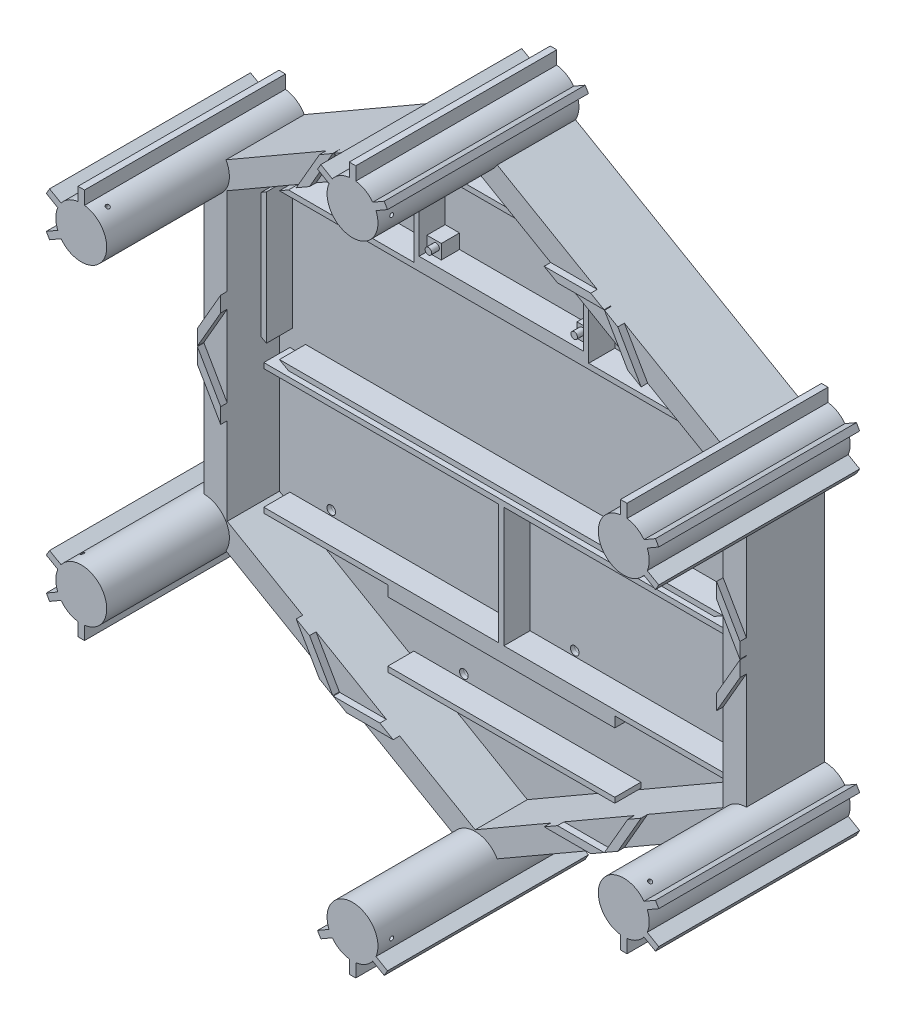
from build123d import *

# Parameters (mm, degrees)
BOSS_EXTRUDE1_DEPTH             = 15
BOSS_EXTRUDE2_REACH             = 163.555
BOSS_EXTRUDE2_DIRECTION_2_DEPTH = 47
CUT_EXTRUDE1_DEPTH              = 20
SKETCH5_W                       = 63
SKETCH5_H                       = 31
SKETCH5_R                       = 1.25
SKETCH5_W_2                     = 87
SKETCH5_H_2                     = 2
BOSS_EXTRUDE3_DEPTH             = 10
SKETCH7_W                       = 5.5
SKETCH7_H                       = 5.5
BOSS_EXTRUDE4_DEPTH             = 7
SKETCH8_R                       = 1.65
CUT_EXTRUDE2_DEPTH              = 1.5
SKETCH9_R                       = 1.8
CUT_EXTRUDE3_DEPTH              = 2.5
BOSS_EXTRUDE9_DEPTH             = 2.5
SKETCH13_R                      = 0.75
CUT_EXTRUDE5_DEPTH              = 267.36610198
SKETCH14_R                      = 0.75
CUT_EXTRUDE6_DEPTH              = 289.120545266
SKETCH15_R                      = 0.75
CUT_EXTRUDE7_DEPTH              = 289.120545266


with BuildPart() as part:
    # Sketch2 → Boss-Extrude1 (new, symmetric)
    with BuildSketch(Plane(origin=(0, 0, 0), x_dir=(0, 1, 0), z_dir=(0, 0, 1))):
        Polygon((120, 0), (60, 103.923048454), (-60, 103.923048454), (-120, 0), (-60, -103.923048454), (60, -103.923048454), align=None)
    extrude(amount=BOSS_EXTRUDE1_DEPTH, both=True)

    # Boss-Extrude2: up to this face of the body (flat: up to its plane)
    boss_extrude2_end = Plane(part.part.faces().sort_by_distance((0, 0, -15))[0])
    # Sketch3 → Boss-Extrude2 (add, up to the picked face)
    with BuildSketch(Plane.XY.offset(15), mode=Mode.PRIVATE) as boss_extrude2_sk1:
        with BuildLine():
            Line((-111.672115566, 54.082698344), (-116.07192316, 51.542468245))
            Line((-116.07192316, 51.542468245), (-117.32192316, 53.707531755))
            Line((-117.32192316, 53.707531755), (-112.922115566, 56.247761853))
            ThreePointArc((-112.922115566, 56.247761853), (-113.673048454, 60), (-112.922115566, 63.752238147))
            Line((-112.922115566, 63.752238147), (-117.32192316, 66.292468245))
            Line((-117.32192316, 66.292468245), (-116.071928769, 68.457524409))
            Line((-116.071928769, 68.457524409), (-111.672121175, 65.917294311))
            ThreePointArc((-111.672121175, 65.917294311), (-108.798052456, 68.443745376), (-105.173048454, 69.669539803))
            Line((-105.173048454, 69.669539803), (-105.173048454, 74.75))
            Line((-105.173048454, 74.75), (-102.673048454, 74.75))
            Line((-102.673048454, 74.75), (-102.673048454, 69.669539803))
            ThreePointArc((-102.673048454, 69.669539803), (-95.479300767, 55.125), (-111.672115566, 54.082698344))
        make_face()
    boss_extrude2_tool1 = split(extrude(boss_extrude2_sk1.sketch, amount=-BOSS_EXTRUDE2_REACH, mode=Mode.PRIVATE), bisect_by=boss_extrude2_end, keep=Keep.BOTH, mode=Mode.PRIVATE)
    # Sketch3 → Boss-Extrude2 (add, up to the picked face)
    with BuildSketch(Plane.XY.offset(15), mode=Mode.PRIVATE) as boss_extrude2_sk2:
        with BuildLine():
            Line((111.672115566, -54.082698344), (116.07192316, -51.542468245))
            Line((116.07192316, -51.542468245), (117.32192316, -53.707531755))
            Line((117.32192316, -53.707531755), (112.922115566, -56.247761853))
            ThreePointArc((112.922115566, -56.247761853), (113.673048454, -60.000004621), (112.92211201, -63.752246677))
            Line((112.92211201, -63.752246677), (117.321919603, -66.292476776))
            Line((117.321919603, -66.292476776), (116.07192316, -68.457531755))
            Line((116.07192316, -68.457531755), (111.672115566, -65.917301656))
            ThreePointArc((111.672115566, -65.917301656), (108.798048454, -68.443747687), (105.173048454, -69.669539803))
            Line((105.173048454, -69.669539803), (105.173048454, -74.75))
            Line((105.173048454, -74.75), (102.673048454, -74.75))
            Line((102.673048454, -74.75), (102.673048454, -69.669539803))
            ThreePointArc((102.673048454, -69.669539803), (95.479300767, -55.125), (111.672115566, -54.082698344))
        make_face()
    boss_extrude2_tool2 = split(extrude(boss_extrude2_sk2.sketch, amount=-BOSS_EXTRUDE2_REACH, mode=Mode.PRIVATE), bisect_by=boss_extrude2_end, keep=Keep.BOTH, mode=Mode.PRIVATE)
    # Sketch3 → Boss-Extrude2 (add, up to the picked face)
    with BuildSketch(Plane.XY.offset(15), mode=Mode.PRIVATE) as boss_extrude2_sk3:
        with BuildLine():
            Line((-8.999067112, 123.752238147), (-13.398874706, 126.292468245))
            Line((-13.398874706, 126.292468245), (-12.148874706, 128.457531755))
            Line((-12.148874706, 128.457531755), (-7.749067112, 125.917301656))
            ThreePointArc((-7.749067112, 125.917301656), (-4.874995998, 128.443749997), (-1.249990834, 129.669540988))
            Line((-1.249990834, 129.669540988), (-1.249990834, 134.750001185))
            Line((-1.249990834, 134.750001185), (1.25, 134.75))
            Line((1.25, 134.75), (1.25, 129.669539803))
            ThreePointArc((1.25, 129.669539803), (4.875, 128.443747687), (7.749067112, 125.917301656))
            Line((7.749067112, 125.917301656), (12.148874706, 128.457531755))
            Line((12.148874706, 128.457531755), (13.398874706, 126.292468245))
            Line((13.398874706, 126.292468245), (8.999067112, 123.752238147))
            ThreePointArc((8.999067112, 123.752238147), (0, 110.25), (-8.999067112, 123.752238147))
        make_face()
    boss_extrude2_tool3 = split(extrude(boss_extrude2_sk3.sketch, amount=-BOSS_EXTRUDE2_REACH, mode=Mode.PRIVATE), bisect_by=boss_extrude2_end, keep=Keep.BOTH, mode=Mode.PRIVATE)
    # Sketch3 → Boss-Extrude2 (add, up to the picked face)
    with BuildSketch(Plane.XY.offset(15), mode=Mode.PRIVATE) as boss_extrude2_sk4:
        with BuildLine():
            Line((-117.32192316, -53.707531755), (-116.07192316, -51.542468245))
            Line((-116.07192316, -51.542468245), (-111.672115566, -54.082698344))
            ThreePointArc((-111.672115566, -54.082698344), (-95.479300767, -55.125), (-102.673048454, -69.669539803))
            Line((-102.673048454, -69.669539803), (-102.673048454, -74.75))
            Line((-102.673048454, -74.75), (-105.173048454, -74.75))
            Line((-105.173048454, -74.75), (-105.173048454, -69.669539803))
            ThreePointArc((-105.173048454, -69.669539803), (-108.798052456, -68.443745376), (-111.672121175, -65.917294311))
            Line((-111.672121175, -65.917294311), (-116.071928769, -68.457524409))
            Line((-116.071928769, -68.457524409), (-117.32192316, -66.292468245))
            Line((-117.32192316, -66.292468245), (-112.922115566, -63.752238147))
            ThreePointArc((-112.922115566, -63.752238147), (-113.673048454, -60), (-112.922115566, -56.247761853))
            Line((-112.922115566, -56.247761853), (-117.32192316, -53.707531755))
        make_face()
    boss_extrude2_tool4 = split(extrude(boss_extrude2_sk4.sketch, amount=-BOSS_EXTRUDE2_REACH, mode=Mode.PRIVATE), bisect_by=boss_extrude2_end, keep=Keep.BOTH, mode=Mode.PRIVATE)
    # Sketch3 → Boss-Extrude2 (add, up to the picked face)
    with BuildSketch(Plane.XY.offset(15), mode=Mode.PRIVATE) as boss_extrude2_sk5:
        with BuildLine():
            Line((102.673048454, 69.669539803), (102.673048454, 74.75))
            Line((102.673048454, 74.75), (105.173048454, 74.75))
            Line((105.173048454, 74.75), (105.173048454, 69.669539803))
            ThreePointArc((105.173048454, 69.669539803), (108.798048454, 68.443747687), (111.672115566, 65.917301656))
            Line((111.672115566, 65.917301656), (116.07192316, 68.457531755))
            Line((116.07192316, 68.457531755), (117.321919603, 66.292476776))
            Line((117.321919603, 66.292476776), (112.92211201, 63.752246677))
            ThreePointArc((112.92211201, 63.752246677), (113.673048454, 60.000004621), (112.922115566, 56.247761853))
            Line((112.922115566, 56.247761853), (117.32192316, 53.707531755))
            Line((117.32192316, 53.707531755), (116.07192316, 51.542468245))
            Line((116.07192316, 51.542468245), (111.672115566, 54.082698344))
            ThreePointArc((111.672115566, 54.082698344), (95.479300767, 55.125), (102.673048454, 69.669539803))
        make_face()
    boss_extrude2_tool5 = split(extrude(boss_extrude2_sk5.sketch, amount=-BOSS_EXTRUDE2_REACH, mode=Mode.PRIVATE), bisect_by=boss_extrude2_end, keep=Keep.BOTH, mode=Mode.PRIVATE)
    # Sketch3 → Boss-Extrude2 (add, up to the picked face)
    with BuildSketch(Plane.XY.offset(15), mode=Mode.PRIVATE) as boss_extrude2_sk6:
        with BuildLine():
            Line((8.999067112, -123.752238147), (13.398874706, -126.292468245))
            Line((13.398874706, -126.292468245), (12.148874706, -128.457531755))
            Line((12.148874706, -128.457531755), (7.749067112, -125.917301656))
            ThreePointArc((7.749067112, -125.917301656), (4.875, -128.443747687), (1.25, -129.669539803))
            Line((1.25, -129.669539803), (1.25, -134.75))
            Line((1.25, -134.75), (-1.249990834, -134.750001185))
            Line((-1.249990834, -134.750001185), (-1.249990834, -129.669540988))
            ThreePointArc((-1.249990834, -129.669540988), (-4.874995998, -128.443749997), (-7.749067112, -125.917301656))
            Line((-7.749067112, -125.917301656), (-12.148874706, -128.457531755))
            Line((-12.148874706, -128.457531755), (-13.398874706, -126.292468245))
            Line((-13.398874706, -126.292468245), (-8.999067112, -123.752238147))
            ThreePointArc((-8.999067112, -123.752238147), (0, -110.25), (8.999067112, -123.752238147))
        make_face()
    boss_extrude2_tool6 = split(extrude(boss_extrude2_sk6.sketch, amount=-BOSS_EXTRUDE2_REACH, mode=Mode.PRIVATE), bisect_by=boss_extrude2_end, keep=Keep.BOTH, mode=Mode.PRIVATE)
    add(boss_extrude2_tool1.solids().sort_by(Axis((-104.714928, 60.457192, 15), (0, 0, -1)))[0])
    add(boss_extrude2_tool2.solids().sort_by(Axis((104.714928, -60.457192, 15), (0, 0, -1)))[0])
    add(boss_extrude2_tool3.solids().sort_by(Axis((0, 120.914384, 15), (0, 0, -1)))[0])
    add(boss_extrude2_tool4.solids().sort_by(Axis((-104.714928, -60.457192, 15), (0, 0, -1)))[0])
    add(boss_extrude2_tool5.solids().sort_by(Axis((104.714928, 60.457192, 15), (0, 0, -1)))[0])
    add(boss_extrude2_tool6.solids().sort_by(Axis((0, -120.914384, 15), (0, 0, -1)))[0])

    # Sketch3 → Boss-Extrude2 direction 2 (add)
    with BuildSketch(Plane.XY.offset(15)):
        with BuildLine():
            Line((-111.672115566, 54.082698344), (-116.07192316, 51.542468245))
            Line((-116.07192316, 51.542468245), (-117.32192316, 53.707531755))
            Line((-117.32192316, 53.707531755), (-112.922115566, 56.247761853))
            ThreePointArc((-112.922115566, 56.247761853), (-113.673048454, 60), (-112.922115566, 63.752238147))
            Line((-112.922115566, 63.752238147), (-117.32192316, 66.292468245))
            Line((-117.32192316, 66.292468245), (-116.071928769, 68.457524409))
            Line((-116.071928769, 68.457524409), (-111.672121175, 65.917294311))
            ThreePointArc((-111.672121175, 65.917294311), (-108.798052456, 68.443745376), (-105.173048454, 69.669539803))
            Line((-105.173048454, 69.669539803), (-105.173048454, 74.75))
            Line((-105.173048454, 74.75), (-102.673048454, 74.75))
            Line((-102.673048454, 74.75), (-102.673048454, 69.669539803))
            ThreePointArc((-102.673048454, 69.669539803), (-95.479300767, 55.125), (-111.672115566, 54.082698344))
        make_face()
        with BuildLine():
            Line((111.672115566, -54.082698344), (116.07192316, -51.542468245))
            Line((116.07192316, -51.542468245), (117.32192316, -53.707531755))
            Line((117.32192316, -53.707531755), (112.922115566, -56.247761853))
            ThreePointArc((112.922115566, -56.247761853), (113.673048454, -60.000004621), (112.92211201, -63.752246677))
            Line((112.92211201, -63.752246677), (117.321919603, -66.292476776))
            Line((117.321919603, -66.292476776), (116.07192316, -68.457531755))
            Line((116.07192316, -68.457531755), (111.672115566, -65.917301656))
            ThreePointArc((111.672115566, -65.917301656), (108.798048454, -68.443747687), (105.173048454, -69.669539803))
            Line((105.173048454, -69.669539803), (105.173048454, -74.75))
            Line((105.173048454, -74.75), (102.673048454, -74.75))
            Line((102.673048454, -74.75), (102.673048454, -69.669539803))
            ThreePointArc((102.673048454, -69.669539803), (95.479300767, -55.125), (111.672115566, -54.082698344))
        make_face()
        with BuildLine():
            Line((-8.999067112, 123.752238147), (-13.398874706, 126.292468245))
            Line((-13.398874706, 126.292468245), (-12.148874706, 128.457531755))
            Line((-12.148874706, 128.457531755), (-7.749067112, 125.917301656))
            ThreePointArc((-7.749067112, 125.917301656), (-4.874995998, 128.443749997), (-1.249990834, 129.669540988))
            Line((-1.249990834, 129.669540988), (-1.249990834, 134.750001185))
            Line((-1.249990834, 134.750001185), (1.25, 134.75))
            Line((1.25, 134.75), (1.25, 129.669539803))
            ThreePointArc((1.25, 129.669539803), (4.875, 128.443747687), (7.749067112, 125.917301656))
            Line((7.749067112, 125.917301656), (12.148874706, 128.457531755))
            Line((12.148874706, 128.457531755), (13.398874706, 126.292468245))
            Line((13.398874706, 126.292468245), (8.999067112, 123.752238147))
            ThreePointArc((8.999067112, 123.752238147), (0, 110.25), (-8.999067112, 123.752238147))
        make_face()
        with BuildLine():
            Line((-117.32192316, -53.707531755), (-116.07192316, -51.542468245))
            Line((-116.07192316, -51.542468245), (-111.672115566, -54.082698344))
            ThreePointArc((-111.672115566, -54.082698344), (-95.479300767, -55.125), (-102.673048454, -69.669539803))
            Line((-102.673048454, -69.669539803), (-102.673048454, -74.75))
            Line((-102.673048454, -74.75), (-105.173048454, -74.75))
            Line((-105.173048454, -74.75), (-105.173048454, -69.669539803))
            ThreePointArc((-105.173048454, -69.669539803), (-108.798052456, -68.443745376), (-111.672121175, -65.917294311))
            Line((-111.672121175, -65.917294311), (-116.071928769, -68.457524409))
            Line((-116.071928769, -68.457524409), (-117.32192316, -66.292468245))
            Line((-117.32192316, -66.292468245), (-112.922115566, -63.752238147))
            ThreePointArc((-112.922115566, -63.752238147), (-113.673048454, -60), (-112.922115566, -56.247761853))
            Line((-112.922115566, -56.247761853), (-117.32192316, -53.707531755))
        make_face()
        with BuildLine():
            Line((102.673048454, 69.669539803), (102.673048454, 74.75))
            Line((102.673048454, 74.75), (105.173048454, 74.75))
            Line((105.173048454, 74.75), (105.173048454, 69.669539803))
            ThreePointArc((105.173048454, 69.669539803), (108.798048454, 68.443747687), (111.672115566, 65.917301656))
            Line((111.672115566, 65.917301656), (116.07192316, 68.457531755))
            Line((116.07192316, 68.457531755), (117.321919603, 66.292476776))
            Line((117.321919603, 66.292476776), (112.92211201, 63.752246677))
            ThreePointArc((112.92211201, 63.752246677), (113.673048454, 60.000004621), (112.922115566, 56.247761853))
            Line((112.922115566, 56.247761853), (117.32192316, 53.707531755))
            Line((117.32192316, 53.707531755), (116.07192316, 51.542468245))
            Line((116.07192316, 51.542468245), (111.672115566, 54.082698344))
            ThreePointArc((111.672115566, 54.082698344), (95.479300767, 55.125), (102.673048454, 69.669539803))
        make_face()
        with BuildLine():
            Line((8.999067112, -123.752238147), (13.398874706, -126.292468245))
            Line((13.398874706, -126.292468245), (12.148874706, -128.457531755))
            Line((12.148874706, -128.457531755), (7.749067112, -125.917301656))
            ThreePointArc((7.749067112, -125.917301656), (4.875, -128.443747687), (1.25, -129.669539803))
            Line((1.25, -129.669539803), (1.25, -134.75))
            Line((1.25, -134.75), (-1.249990834, -134.750001185))
            Line((-1.249990834, -134.750001185), (-1.249990834, -129.669540988))
            ThreePointArc((-1.249990834, -129.669540988), (-4.874995998, -128.443749997), (-7.749067112, -125.917301656))
            Line((-7.749067112, -125.917301656), (-12.148874706, -128.457531755))
            Line((-12.148874706, -128.457531755), (-13.398874706, -126.292468245))
            Line((-13.398874706, -126.292468245), (-8.999067112, -123.752238147))
            ThreePointArc((-8.999067112, -123.752238147), (0, -110.25), (8.999067112, -123.752238147))
        make_face()
    extrude(amount=BOSS_EXTRUDE2_DIRECTION_2_DEPTH)

    # Sketch4 → Cut-Extrude1 (cut)
    with BuildSketch(Plane.XY.offset(15)):
        Polygon((0, 109.696551146), (-95, 54.848275573), (-95, -54.848275573), (0, -109.696551146), (95, -54.848275573), (95, 54.848275573), align=None)
    extrude(amount=-CUT_EXTRUDE1_DEPTH, mode=Mode.SUBTRACT)

    # Sketch5 → Boss-Extrude3 (add)
    with BuildSketch(Plane.XY.offset(-5)):
        Polygon((-1, -53.151724427), (-91, -53.151724427), (-91, -55.151724427), (-43.5, -55.151724427), (-43.5, -59.151724427), (43.5, -59.151724427), (43.5, -55.151724427), (91, -55.151724427), (91, -53.151724427), (1, -53.151724427), (1, -7.151724427), (91, -7.151724427), (91, -5.151724427), (-91, -5.151724427), (-91, -7.151724427), (-1, -7.151724427), align=None)
        Polygon((-90, 1.735026919), (-90, 51.961524227), (-92, 50.806823689), (-92, 2.889727457), align=None)
        Polygon((90, 1.735026919), (90, 51.961524227), (92, 50.806823689), (92, 2.889727457), align=None)
        Polygon((33.5, 56.848275573), (33.5, 92.848275573), (-33.5, 92.848275573), (-33.5, 56.848275573), (-81.535898385, 56.848275573), (-85, 54.848275573), (85, 54.848275573), (81.535898385, 56.848275573), align=None)
        with Locations((0, 75.348275573)):
            Rectangle(SKETCH5_W, SKETCH5_H, mode=Mode.SUBTRACT)
        with Locations((-27.95, 63.298275573)):
            Circle(SKETCH5_R)
        with Locations((27.95, 63.298275573)):
            Circle(SKETCH5_R)
        with Locations((27.95, 86.898275573)):
            Circle(SKETCH5_R)
        with Locations((-27.95, 86.898275573)):
            Circle(SKETCH5_R)
        with Locations((0, -83.151724427)):
            Rectangle(SKETCH5_W_2, SKETCH5_H_2)
        Polygon((-81.535898385, -3.151724427), (81.535898385, -3.151724427), (85, -1.151724427), (-85, -1.151724427), align=None)
    extrude(amount=BOSS_EXTRUDE3_DEPTH)

    # Sketch7 → Boss-Extrude4 (add)
    with BuildSketch(Plane.XY.offset(-5)):
        with Locations((28.75, 88.098275573)):
            Rectangle(SKETCH7_W, SKETCH7_H)
        with Locations((-28.75, 88.098275573)):
            Rectangle(SKETCH7_W, SKETCH7_H)
        with Locations((-28.75, 62.598275573)):
            Rectangle(SKETCH7_W, SKETCH7_H)
        with Locations((28.75, 62.598275573)):
            Rectangle(SKETCH7_W, SKETCH7_H)
    extrude(amount=BOSS_EXTRUDE4_DEPTH)

    # Sketch8 → Cut-Extrude2 (cut)
    with BuildSketch(Plane.XY.offset(-5)):
        with Locations((-75.15, -51.151724427)):
            Circle(SKETCH8_R)
        with Locations((-19.85, -9.151724427)):
            Circle(SKETCH8_R)
        with Locations((18.15, -51.151724427)):
            Circle(SKETCH8_R)
        with Locations((71.85, -9.151724427)):
            Circle(SKETCH8_R)
        with Locations((-24.35, -80.151724427)):
            Circle(SKETCH8_R)
        with Locations((24.35, -61.151724427)):
            Circle(SKETCH8_R)
    extrude(amount=-CUT_EXTRUDE2_DEPTH, mode=Mode.SUBTRACT)

    # Sketch9 → Cut-Extrude3 (cut)
    with BuildSketch(Plane.XY.offset(-6.5)):
        with Locations((-75.15, -51.151724427)):
            Circle(SKETCH9_R)
        with Locations((-19.85, -9.151724427)):
            Circle(SKETCH9_R)
        with Locations((18.15, -51.151724427)):
            Circle(SKETCH9_R)
        with Locations((24.35, -61.151724427)):
            Circle(SKETCH9_R)
        with Locations((-24.35, -80.151724427)):
            Circle(SKETCH9_R)
        with Locations((71.85, -9.151724427)):
            Circle(SKETCH9_R)
    extrude(amount=-CUT_EXTRUDE3_DEPTH, mode=Mode.SUBTRACT)

    # Sketch10 → Boss-Extrude9 (add)
    with BuildSketch(Plane.XY.offset(15)):
        Polygon((60.971175222, -74.494826719), (52.048126767, -89.95), (57.15767665, -87), (66.080725104, -71.544826719), align=None)
        Polygon((-66.080725104, -71.544826719), (-57.15767665, -87), (-52.048126767, -89.95), (-60.971175222, -74.494826719), align=None)
        Polygon((-46.765371804, -93), (-28.919274896, -93), (-34.028824778, -90.05), (-51.874921687, -90.05), align=None)
        Polygon((95, -15.555173281), (95, -21.455173281), (103.923048454, -6), (103.923048454, -0.1), align=None)
        Polygon((-95, -15.555173281), (-103.923048454, -0.1), (-103.923048454, -6), (-95, -21.455173281), align=None)
        Polygon((51.874921687, -90.05), (34.028824778, -90.05), (28.919274896, -93), (46.765371804, -93), align=None)
        Polygon((103.923048454, 0.1), (103.923048454, 6), (95, 21.455173281), (95, 15.555173281), align=None)
        Polygon((34.028824778, 90.05), (51.874921687, 90.05), (46.765371804, 93), (28.919274896, 93), align=None)
        Polygon((52.048126767, 89.95), (60.971175222, 74.494826719), (66.080725104, 71.544826719), (57.15767665, 87), align=None)
        Polygon((-103.923048454, 0.1), (-95, 15.555173281), (-95, 21.455173281), (-103.923048454, 6), align=None)
        Polygon((-52.048126767, 89.95), (-57.15767665, 87), (-66.080725104, 71.544826719), (-60.971175222, 74.494826719), align=None)
        Polygon((-34.028824778, 90.05), (-28.919274896, 93), (-46.765371804, 93), (-51.874921687, 90.05), align=None)
    extrude(amount=BOSS_EXTRUDE9_DEPTH)

    # Sketch13 → Cut-Extrude5 (cut, through all)
    with BuildSketch(Plane.YZ.offset(103.923048454)):
        with Locations((-120, 56.75)):
            Circle(SKETCH13_R)
        with Locations((120, 56.75)):
            Circle(SKETCH13_R)
    extrude(amount=-CUT_EXTRUDE5_DEPTH, mode=Mode.SUBTRACT)

    # Sketch14 → Cut-Extrude6 (cut, through all)
    with BuildSketch(Plane(origin=(51.961524227, -90, 0), x_dir=(0.8660254037844357, 0.5000000000000052, 0), z_dir=(0.5000000000000052, -0.8660254037844357, 0))):
        with Locations((-120, 56.75)):
            Circle(SKETCH14_R)
        with Locations((120, 56.75)):
            Circle(SKETCH14_R)
    extrude(amount=-CUT_EXTRUDE6_DEPTH, mode=Mode.SUBTRACT)

    # Sketch15 → Cut-Extrude7 (cut, through all)
    with BuildSketch(Plane(origin=(-51.961524227, -90, 0), x_dir=(0.8660254037844417, -0.4999999999999949, 0), z_dir=(-0.4999999999999949, -0.8660254037844417, 0))):
        with Locations((-120, 56.75)):
            Circle(SKETCH15_R)
        with Locations((120, 56.75)):
            Circle(SKETCH15_R)
    extrude(amount=-CUT_EXTRUDE7_DEPTH, mode=Mode.SUBTRACT)


solid = part.part
